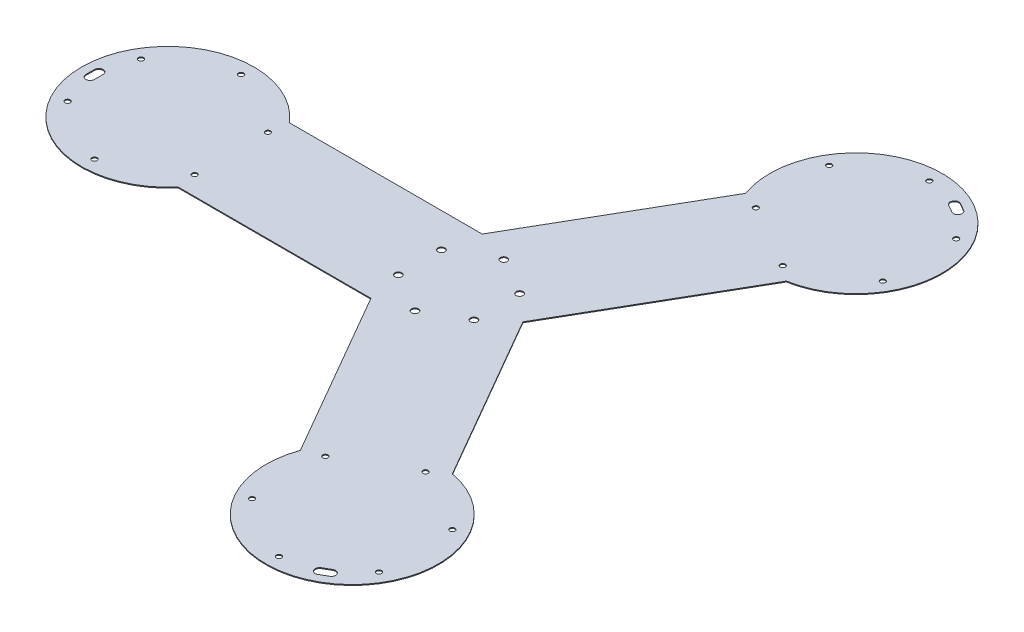
from build123d import *

# Parameters (mm, degrees)
SKETCH1_R           = 3
SKETCH1_R_2         = 4
BOSS_EXTRUDE1_DEPTH = 1


with BuildPart() as part:
    # Sketch1 → Boss-Extrude1 (new body)
    with BuildSketch(Plane(origin=(0, 0, 0), x_dir=(1, 0, 0), z_dir=(0, 1, 0))):
        with BuildLine():
            Line((-37.239092363, -64.5), (-260.820835382, -64.5))
            ThreePointArc((-260.820835382, -64.5), (-437.239092363, 0), (-260.820835382, 64.5))
            Line((-260.820835382, 64.5), (-37.239092363, 64.5))
            Line((-37.239092363, 64.5), (74.551779147, 258.127469277))
            ThreePointArc((74.551779147, 258.127469277), (218.619546181, 378.660161514), (186.269056235, 193.627469277))
            Line((186.269056235, 193.627469277), (74.478184725, 0))
            Line((74.478184725, 0), (186.269056235, -193.627469277))
            ThreePointArc((186.269056235, -193.627469277), (218.619546181, -378.660161514), (74.551779147, -258.127469277))
            Line((74.551779147, -258.127469277), (-37.239092363, -64.5))
        make_face()
        with Locations((-337.239092363, 85)):
            Circle(SKETCH1_R, mode=Mode.SUBTRACT)
        with Locations((-263.626933041, 42.5)):
            Circle(SKETCH1_R, mode=Mode.SUBTRACT)
        with Locations((-263.626933041, -42.5)):
            Circle(SKETCH1_R, mode=Mode.SUBTRACT)
        with Locations((-337.239092363, -85)):
            Circle(SKETCH1_R, mode=Mode.SUBTRACT)
        with Locations((-410.851251684, -42.5)):
            Circle(SKETCH1_R, mode=Mode.SUBTRACT)
        with Locations((-410.851251684, 42.5)):
            Circle(SKETCH1_R, mode=Mode.SUBTRACT)
        with Locations((168.619546181, 207.057621135)):
            Circle(SKETCH1_R, mode=Mode.SUBTRACT)
        with Locations((242.231705503, 249.557621135)):
            Circle(SKETCH1_R, mode=Mode.SUBTRACT)
        with Locations((242.231705503, 334.557621135)):
            Circle(SKETCH1_R, mode=Mode.SUBTRACT)
        with Locations((168.619546181, 377.057621135)):
            Circle(SKETCH1_R, mode=Mode.SUBTRACT)
        with Locations((95.00738686, 334.557621135)):
            Circle(SKETCH1_R, mode=Mode.SUBTRACT)
        with Locations((95.00738686, 249.557621135)):
            Circle(SKETCH1_R, mode=Mode.SUBTRACT)
        with Locations((95.00738686, -249.557621135)):
            Circle(SKETCH1_R, mode=Mode.SUBTRACT)
        with Locations((95.00738686, -334.557621135)):
            Circle(SKETCH1_R, mode=Mode.SUBTRACT)
        with Locations((168.619546181, -377.057621135)):
            Circle(SKETCH1_R, mode=Mode.SUBTRACT)
        with Locations((242.231705503, -334.557621135)):
            Circle(SKETCH1_R, mode=Mode.SUBTRACT)
        with Locations((242.231705503, -249.557621135)):
            Circle(SKETCH1_R, mode=Mode.SUBTRACT)
        with Locations((168.619546181, -207.057621135)):
            Circle(SKETCH1_R, mode=Mode.SUBTRACT)
        with Locations((-45, -25)):
            Circle(SKETCH1_R_2, mode=Mode.SUBTRACT)
        with Locations((-45, 25)):
            Circle(SKETCH1_R_2, mode=Mode.SUBTRACT)
        with Locations((44.150635095, 26.47114317)):
            Circle(SKETCH1_R_2, mode=Mode.SUBTRACT)
        with Locations((0.849364905, 51.47114317)):
            Circle(SKETCH1_R_2, mode=Mode.SUBTRACT)
        with Locations((0.849364905, -51.47114317)):
            Circle(SKETCH1_R_2, mode=Mode.SUBTRACT)
        with Locations((44.150635095, -26.47114317)):
            Circle(SKETCH1_R_2, mode=Mode.SUBTRACT)
        with BuildLine():
            Line((-427.239092363, -5), (-427.239092363, 5))
            ThreePointArc((-427.239092363, 5), (-422.239092363, 10), (-417.239092363, 5))
            Line((-417.239092363, 5), (-417.239092363, -5))
            ThreePointArc((-417.239092363, -5), (-422.239092363, -10), (-427.239092363, -5))
        make_face(mode=Mode.SUBTRACT)
        with BuildLine():
            Line((209.289419162, 372.499907476), (217.9496732, 367.499907476))
            ThreePointArc((217.9496732, 367.499907476), (219.779800219, 360.669780457), (212.9496732, 358.839653438))
            Line((212.9496732, 358.839653438), (204.289419162, 363.839653438))
            ThreePointArc((204.289419162, 363.839653438), (202.459292144, 370.669780457), (209.289419162, 372.499907476))
        make_face(mode=Mode.SUBTRACT)
        with BuildLine():
            Line((217.9496732, -367.499907476), (209.289419162, -372.499907476))
            ThreePointArc((209.289419162, -372.499907476), (202.459292144, -370.669780457), (204.289419162, -363.839653438))
            Line((204.289419162, -363.839653438), (212.9496732, -358.839653438))
            ThreePointArc((212.9496732, -358.839653438), (219.779800219, -360.669780457), (217.9496732, -367.499907476))
        make_face(mode=Mode.SUBTRACT)
    extrude(amount=BOSS_EXTRUDE1_DEPTH)


solid = part.part
